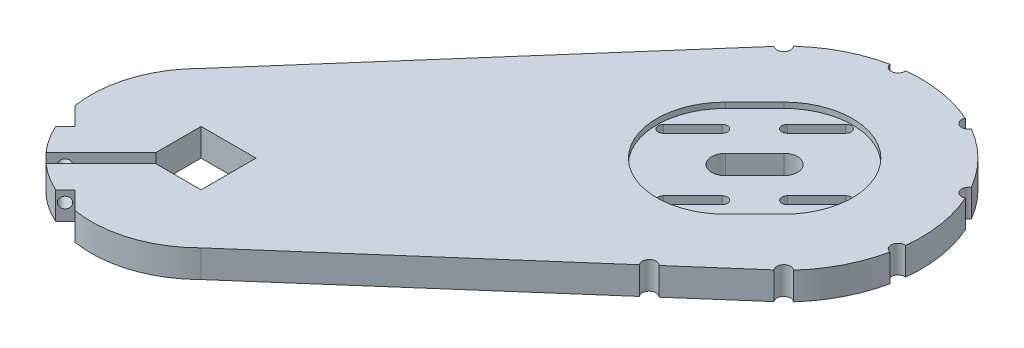
from build123d import *

# Parameters (mm, degrees)
ESQUISSE1_W                  = 20
ESQUISSE1_H                  = 20
BOSS_EXTRU_1_DEPTH           = 10
ENL_V_MAT_EXTRU_1_DEPTH      = 11
ESQUISSE4_R                  = 2
ENL_V_MAT_EXTRU_2_DEPTH      = 142.139610307
ENL_V_MAT_EXTRU_2_DEPTH_BACK = 137.139610307
ENL_V_MAT_EXTRU_3_DEPTH      = 11.0000001
ENL_V_MAT_EXTRU_4_DEPTH      = 11
ENL_V_MAT_EXTRU_5_DEPTH      = 2
ESQUISSE9_R                  = 2.5
ENL_V_MAT_EXTRU_6_DEPTH      = 11


with BuildPart() as part:
    # Esquisse1 → Boss.-Extru.1 (new body)
    with BuildSketch(Plane(origin=(0, 0, 0), x_dir=(1, 0, 0), z_dir=(0, 1, 0))):
        with BuildLine():
            Line((-28.284271247, 28.284271247), (70.710678119, 141.421356237))
            ThreePointArc((70.710678119, 141.421356237), (141.421356237, 141.421356237), (141.421356237, 70.710678119))
            Line((141.421356237, 70.710678119), (28.284271247, -28.284271247))
            ThreePointArc((28.284271247, -28.284271247), (-28.284271247, -28.284271247), (-28.284271247, 28.284271247))
        make_face()
        Rectangle(ESQUISSE1_W, ESQUISSE1_H, mode=Mode.SUBTRACT)
    extrude(amount=BOSS_EXTRU_1_DEPTH)

    # Esquisse3 → Enlèv. mat.-Extru.1 (cut, through all)
    with BuildSketch(Plane(origin=(0, 10, 0), x_dir=(1, 0, 0), z_dir=(0, 1, 0))):
        Polygon((-8.232233047, -11.767766953), (-27.234385984, -30.76991989), (-30.76991989, -27.234385984), (-11.767766953, -8.232233047), (-9.726873799, -6.191339893), (-6.191339893, -9.726873799), align=None)
    extrude(amount=-ENL_V_MAT_EXTRU_1_DEPTH, mode=Mode.SUBTRACT)

    # Esquisse4 → Enlèv. mat.-Extru.2 (cut, two sides)
    with BuildSketch(Plane(origin=(1.767766953, 0, 1.767766953), x_dir=(-0.707106781, 0, 0.707106781), z_dir=(-0.707106781, 0, -0.707106781))) as enl_v_mat_extru_2_sk:
        with Locations((35.022819071, 6)):
            Circle(ESQUISSE4_R)
    extrude(amount=ENL_V_MAT_EXTRU_2_DEPTH, mode=Mode.SUBTRACT)
    extrude(enl_v_mat_extru_2_sk.sketch, amount=-ENL_V_MAT_EXTRU_2_DEPTH_BACK, mode=Mode.SUBTRACT)

    # Esquisse5 → Enlèv. mat.-Extru.3 (cut, through all)
    with BuildSketch(Plane(origin=(0, 10, 0), x_dir=(1, 0, 0), z_dir=(0, 1, 0))):
        Polygon((-34.683660608, -14.703220533), (-36.451427561, -16.470987486), (-40.908486709, -7.777625617), (-39.491104164, -6.360243072), (-32.915893655, -12.93545358), align=None)
        Polygon((-7.777625617, -40.908486709), (-6.360243072, -39.491104164), (-12.93545358, -32.915893655), (-14.703220533, -34.683660608), (-16.470987486, -36.451427561), align=None)
    extrude(amount=-ENL_V_MAT_EXTRU_3_DEPTH, mode=Mode.SUBTRACT)

    # Esquisse7 → Enlèv. mat.-Extru.4 (cut, through all)
    with BuildSketch(Plane(origin=(0, 10, 0), x_dir=(1, 0, 0), z_dir=(0, 1, 0))):
        with BuildLine():
            Line((91.923881554, 98.994949366), (102.530483272, 109.601551084))
            ThreePointArc((102.530483272, 109.601551084), (109.601551084, 109.601551084), (109.601551084, 102.530483272))
            Line((109.601551084, 102.530483272), (98.994949366, 91.923881554))
            ThreePointArc((98.994949366, 91.923881554), (91.923881554, 91.923881554), (91.923881554, 98.994949366))
        make_face()
        with BuildLine():
            Line((94.045201898, 119.373629023), (104.651803616, 129.98023074))
            ThreePointArc((104.651803616, 129.98023074), (107.48023074, 129.98023074), (107.48023074, 127.151803616))
            Line((107.48023074, 127.151803616), (96.873629023, 116.545201898))
            ThreePointArc((96.873629023, 116.545201898), (94.045201898, 116.545201898), (94.045201898, 119.373629023))
        make_face()
        with BuildLine():
            Line((71.545201898, 96.873629023), (82.151803616, 107.48023074))
            ThreePointArc((82.151803616, 107.48023074), (84.98023074, 107.48023074), (84.98023074, 104.651803616))
            Line((84.98023074, 104.651803616), (74.373629023, 94.045201898))
            ThreePointArc((74.373629023, 94.045201898), (71.545201898, 94.045201898), (71.545201898, 96.873629023))
        make_face()
        with BuildLine():
            Line((119.373629023, 94.045201898), (129.98023074, 104.651803616))
            ThreePointArc((129.98023074, 104.651803616), (129.98023074, 107.48023074), (127.151803616, 107.48023074))
            Line((127.151803616, 107.48023074), (116.545201898, 96.873629023))
            ThreePointArc((116.545201898, 96.873629023), (116.545201898, 94.045201898), (119.373629023, 94.045201898))
        make_face()
        with BuildLine():
            Line((96.873629023, 71.545201898), (107.48023074, 82.151803616))
            ThreePointArc((107.48023074, 82.151803616), (107.48023074, 84.98023074), (104.651803616, 84.98023074))
            Line((104.651803616, 84.98023074), (94.045201898, 74.373629023))
            ThreePointArc((94.045201898, 74.373629023), (94.045201898, 71.545201898), (96.873629023, 71.545201898))
        make_face()
    extrude(amount=-ENL_V_MAT_EXTRU_4_DEPTH, mode=Mode.SUBTRACT)

    # Esquisse8 → Enlèv. mat.-Extru.5 (cut)
    with BuildSketch(Plane(origin=(0, 10, 0), x_dir=(1, 0, 0), z_dir=(0, 1, 0))):
        with BuildLine():
            Line((123.743686708, 88.388347648), (113.13708499, 77.781745931))
            ThreePointArc((113.13708499, 77.781745931), (77.781745931, 77.781745931), (77.781745931, 113.13708499))
            Line((77.781745931, 113.13708499), (88.388347648, 123.743686708))
            ThreePointArc((88.388347648, 123.743686708), (123.743686708, 123.743686708), (123.743686708, 88.388347648))
        make_face()
    extrude(amount=-ENL_V_MAT_EXTRU_5_DEPTH, mode=Mode.SUBTRACT)

    # Esquisse9 → Enlèv. mat.-Extru.6 (cut, through all)
    with BuildSketch(Plane(origin=(0, 0, 0), x_dir=(-1, 0, 0), z_dir=(0, -1, 0))):
        with Locations((-70.710678119, 141.421356237)):
            Circle(ESQUISSE9_R)
        with Locations((-98.244293926, 155.450434208)):
            Circle(ESQUISSE9_R)
        with Locations((-128.765542165, 150.616343387)):
            Circle(ESQUISSE9_R)
        with Locations((-150.616343387, 128.765542165)):
            Circle(ESQUISSE9_R)
        with Locations((-155.450434208, 98.244293926)):
            Circle(ESQUISSE9_R)
        with Locations((-141.421356237, 70.710678119)):
            Circle(ESQUISSE9_R)
        with Locations((-115.287543419, 47.843591903)):
            Circle(ESQUISSE9_R)
    extrude(amount=-ENL_V_MAT_EXTRU_6_DEPTH, mode=Mode.SUBTRACT)


solid = part.part
